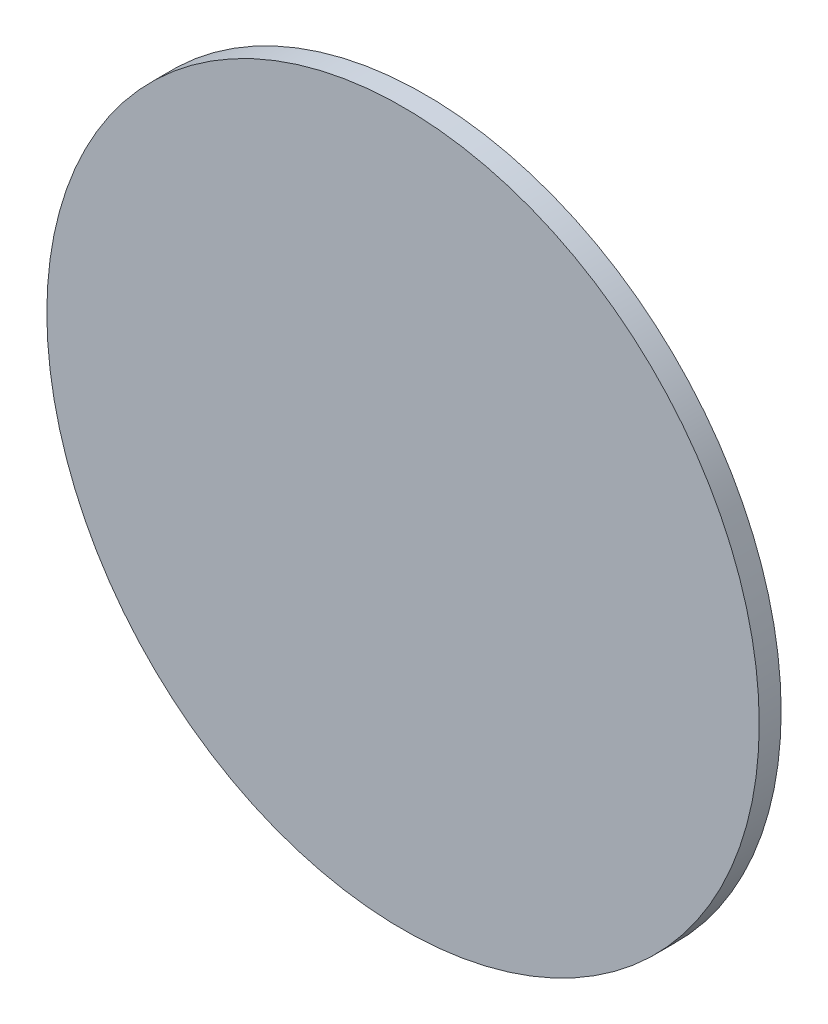
from build123d import *

# Parameters (mm, degrees)
SKETCH1_R           = 13
BOSS_EXTRUDE1_DEPTH = 0.8


with BuildPart() as part:
    # Sketch1 → Boss-Extrude1 (new body)
    with BuildSketch(Plane.XY):
        Circle(SKETCH1_R)
    extrude(amount=BOSS_EXTRUDE1_DEPTH)


solid = part.part
